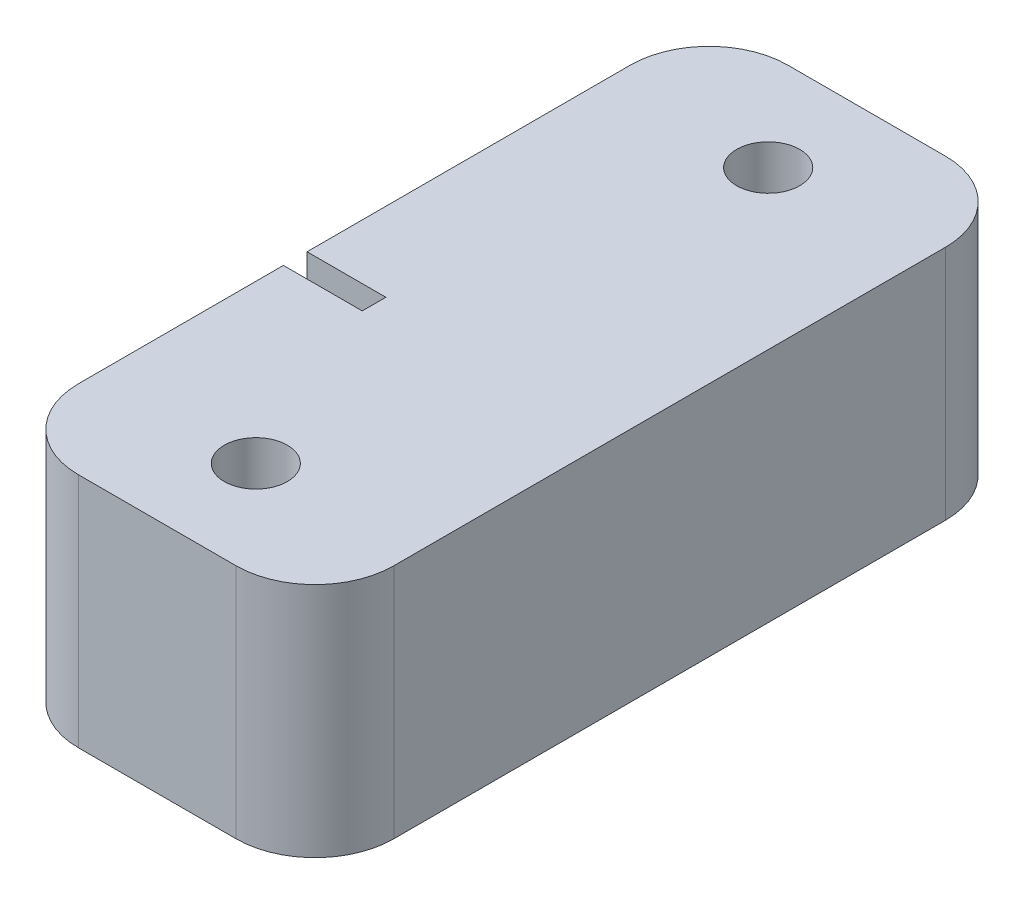
from build123d import *

# Parameters (mm, degrees)
SKETCH2_W           = 40
SKETCH2_H           = 90
BOSS_EXTRUDE1_DEPTH = 30
SKETCH3_R           = 4
CUT_EXTRUDE1_DEPTH  = 20
SKETCH4_R           = 4
SKETCH4_R_2         = 2.5
SKETCH4_W           = 3
SKETCH4_H           = 12
CUT_EXTRUDE2_DEPTH  = 10
FILLET1_R           = 10


with BuildPart() as part:
    # Sketch2 → Boss-Extrude1 (new body)
    with BuildSketch(Plane(origin=(0, 0, 0), x_dir=(1, 0, 0), z_dir=(0, 1, 0))):
        with Locations((-3.52238806, 4.76119403)):
            Rectangle(SKETCH2_W, SKETCH2_H)
    extrude(amount=BOSS_EXTRUDE1_DEPTH)

    # Sketch3 → Cut-Extrude1 (cut)
    with BuildSketch(Plane(origin=(0, 30, 0), x_dir=(1, 0, 0), z_dir=(0, 1, 0))):
        with Locations((-3.52238806, 37.26119403)):
            Circle(SKETCH3_R)
        with Locations((-3.52238806, -27.73880597)):
            Circle(SKETCH3_R)
    extrude(amount=-CUT_EXTRUDE1_DEPTH, mode=Mode.SUBTRACT)

    # Sketch4 → Cut-Extrude2 (cut)
    with BuildSketch(Plane.ZY.offset(23.52238806)):
        with Locations((2.73880597, 15)):
            Circle(SKETCH4_R)
        with Locations((2.73880597, 15)):
            Circle(SKETCH4_R_2, mode=Mode.SUBTRACT)
        with Locations((2.73880597, 24)):
            Rectangle(SKETCH4_W, SKETCH4_H)
    extrude(amount=-CUT_EXTRUDE2_DEPTH, mode=Mode.SUBTRACT)

    # Fillet1
    fillet1_edges = [part.edges().sort_by_distance(p)[0] for p in [
        (-23.52238806, 15, -49.76119403),
        (16.47761194, 15, -49.76119403),
        (16.47761194, 15, 40.23880597),
        (-23.52238806, 15, 40.23880597),
    ]]
    fillet(fillet1_edges, radius=FILLET1_R)


solid = part.part
